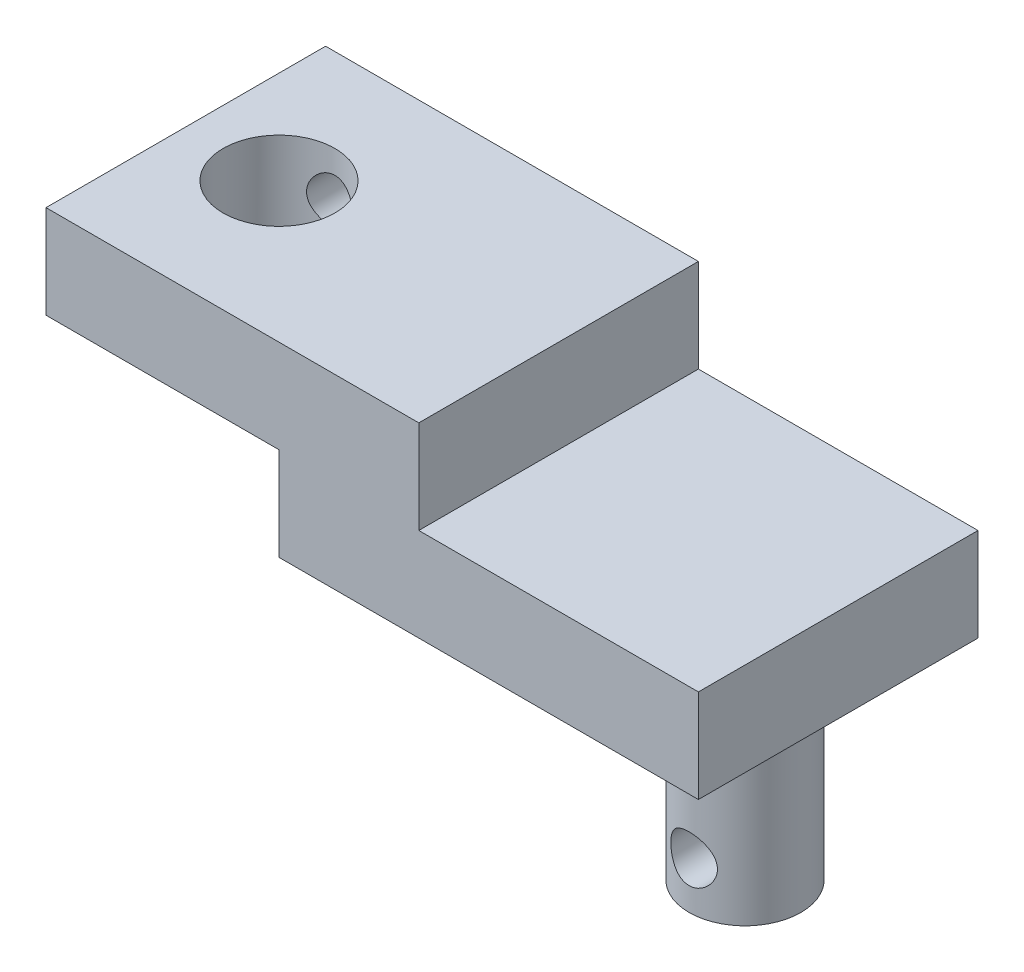
from build123d import *

# Parameters (mm, degrees)
EXTRUDE_1_DEPTH          = 15
CUT_EXTRUDE_1_REACH      = 49.17
SKETCH_2_R               = 6
SKETCH_3_R               = 6
EXTRUDE_2_DEPTH          = 20
SKETCH_4_R               = 2.5
CUT_EXTRUDE_2_DEPTH      = 53.201532545
CUT_EXTRUDE_3_DEPTH      = 53.201532573
CUT_EXTRUDE_3_DEPTH_BACK = 53.201532573
SKETCH_5_R               = 2.5


with BuildPart() as part:
    # 草图1 → 凸台-拉伸1 (new, symmetric)
    with BuildSketch(Plane.XY):
        Polygon((-40, 10), (0, 10), (0, 0), (30, 0), (30, -10), (-15, -10), (-15, 0), (-40, 0), align=None)
    extrude(amount=EXTRUDE_1_DEPTH, both=True)

    # 草图2 → 切除-拉伸1 (cut, up to next)
    with BuildSketch(Plane(origin=(0, 10, 0), x_dir=(1, 0, 0), z_dir=(0, 1, 0)), mode=Mode.PRIVATE) as cut_extrude_1_sk1:
        with Locations((-30, 0)):
            Circle(SKETCH_2_R)
    cut_extrude_1_tool1 = extrude(cut_extrude_1_sk1.sketch, amount=-CUT_EXTRUDE_1_REACH, mode=Mode.PRIVATE) & part.part
    add(cut_extrude_1_tool1.solids().sort_by_distance((-30, 10, 0))[0], mode=Mode.SUBTRACT)

    # 草图3 → 凸台-拉伸2 (add)
    with BuildSketch(Plane.XZ.offset(10)):
        with Locations((20, 0)):
            Circle(SKETCH_3_R)
    extrude(amount=EXTRUDE_2_DEPTH)

    # 草图4 → 切除-拉伸2 (cut, through all)
    with BuildSketch(Plane.XY):
        with Locations((-30, 5)):
            Circle(SKETCH_4_R)
    extrude(amount=-CUT_EXTRUDE_2_DEPTH, mode=Mode.SUBTRACT)

    # 草图5 → 切除-拉伸3 (cut, two sides: drawn at the far end of the back side and taken through both)
    with BuildSketch(Plane(origin=(0, 0, 0), x_dir=(-1, 0, 0), z_dir=(0, 0, -1)).offset(-CUT_EXTRUDE_3_DEPTH_BACK)):
        with Locations((-20, -25)):
            Circle(SKETCH_5_R)
    extrude(amount=CUT_EXTRUDE_3_DEPTH + CUT_EXTRUDE_3_DEPTH_BACK, mode=Mode.SUBTRACT)


solid = part.part
